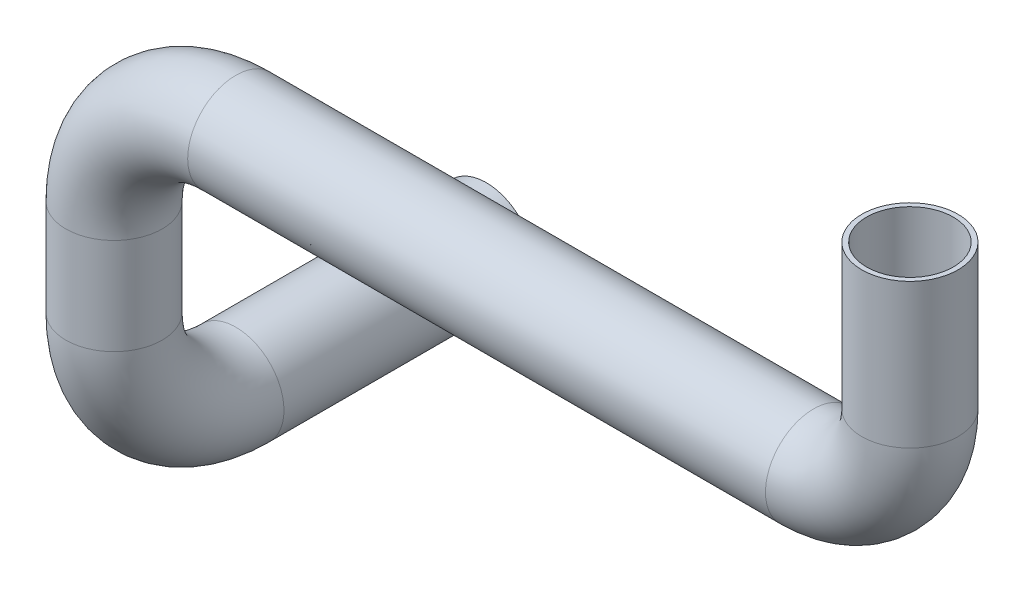
from build123d import *

# Parameters (mm, degrees)
SKETCH2_R = 5
SKETCH5_R = 5
SHELL1_T  = -0.5


with BuildPart() as part:
    # Sweep1: sweep along a path in Sketch1
    with BuildLine(Plane.XY) as sweep1_path:
        Line((40, 25), (40, 10))
        ThreePointArc((40, 10), (37.071067812, 2.928932188), (30, 0))
        Line((30, 0), (-30, 0))
        ThreePointArc((-30, 0), (-38.944900782, -3.705099218), (-42.65, -12.65))
        Line((-42.65, -12.65), (-42.65, -22.65))
    # Sketch2 → Sweep1 (sweep)
    with BuildSketch(Plane(origin=(0, 25, 0), x_dir=(1, 0, 0), z_dir=(0, 1, 0))):
        with Locations((40, 0)):
            Circle(SKETCH2_R)
    sweep(path=sweep1_path.line)

    # Sweep2: sweep along a path in Sketch4
    with BuildLine(Plane(origin=(-42.65, 0, 0), x_dir=(0, 0, -1), z_dir=(1, 0, 0))) as sweep2_path:
        ThreePointArc((0, -22.65), (3.705099218, -31.594900782), (12.65, -35.3))
        Line((12.65, -35.3), (38.65, -35.3))
    # Sketch5 → Sweep2 (sweep)
    with BuildSketch(Plane.XZ.offset(22.65)):
        with Locations((-42.65, 0)):
            Circle(SKETCH5_R)
    sweep(path=sweep2_path.line)

    # Shell1
    shell1_openings = [part.faces().sort_by_distance(p)[0] for p in [
        (-42.65, -35.3, -38.65),
        (40, 25, 0),
    ]]
    offset(amount=SHELL1_T, openings=shell1_openings, kind=Kind.INTERSECTION)


solid = part.part
